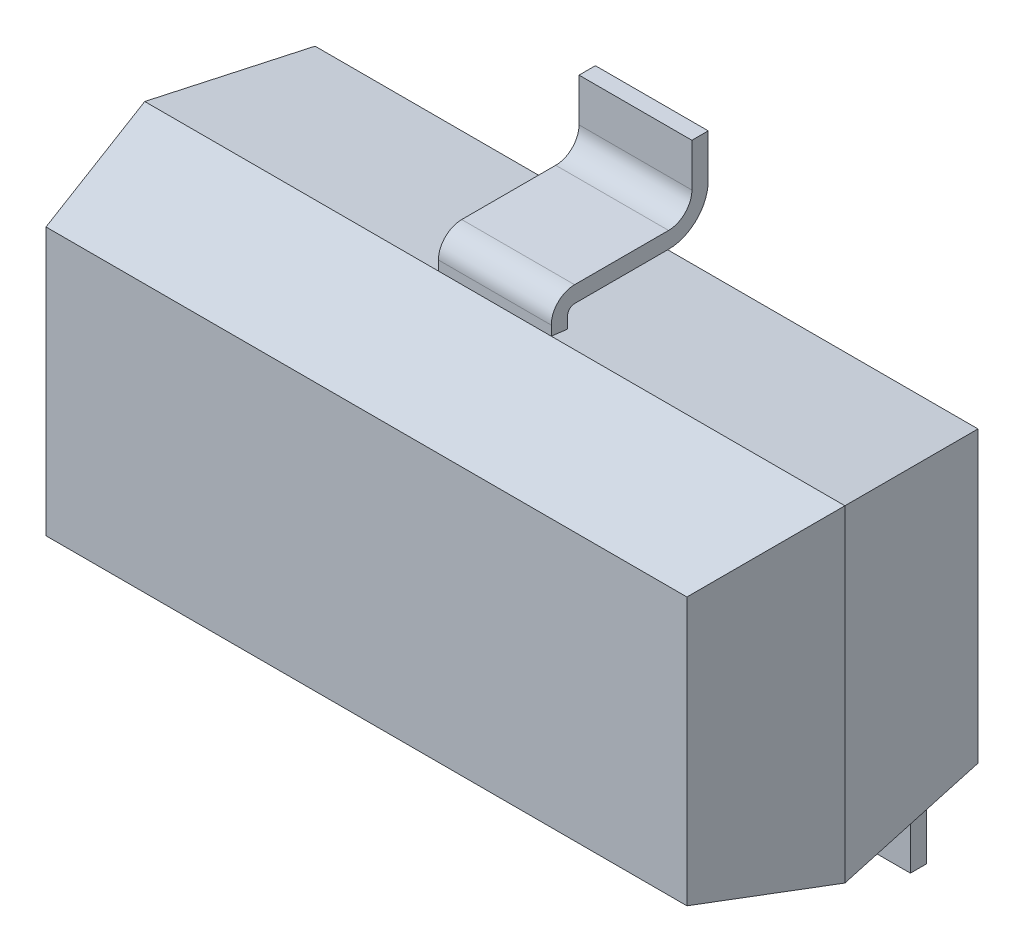
from build123d import *

# Parameters (mm, degrees)
CROQUIS1_W                        = 3
CROQUIS1_H                        = 1.4
SALIENTE_EXTRUIR1_DEPTH           = 0.55
SALIENTE_EXTRUIR1_TAPER           = 13
SALIENTE_EXTRUIR1_OTHER_WAY_DEPTH = 0.65
SALIENTE_EXTRUIR1_OTHER_WAY_TAPER = 7
CROQUIS5_W                        = 0.48350588
CROQUIS5_H                        = 0.55271101
SALIENTE_EXTRUIR5_DEPTH           = 0.69
CORTAR_EXTRUIR2_DEPTH             = 2.69


with BuildPart() as part:
    # Croquis1 → Saliente-Extruir1 (new body)
    with BuildSketch(Plane.XY):
        Rectangle(CROQUIS1_W, CROQUIS1_H)
    extrude(amount=SALIENTE_EXTRUIR1_DEPTH, taper=SALIENTE_EXTRUIR1_TAPER)

    # Croquis1 → Saliente-Extruir1 other way (add)
    with BuildSketch(Plane.XY):
        Rectangle(CROQUIS1_W, CROQUIS1_H)
    extrude(amount=-SALIENTE_EXTRUIR1_OTHER_WAY_DEPTH, taper=SALIENTE_EXTRUIR1_OTHER_WAY_TAPER)

    # Croquis5 → Saliente-Extruir5 (add)
    with BuildSketch(Plane.XY):
        with Locations((-0.936243204, -0.849378)):
            Rectangle(CROQUIS5_W, CROQUIS5_H)
        with Locations((0.936243204, -0.849378)):
            Rectangle(CROQUIS5_W, CROQUIS5_H)
        with Locations((0, 0.849378)):
            Rectangle(CROQUIS5_W, CROQUIS5_H)
    extrude(amount=-SALIENTE_EXTRUIR5_DEPTH)

    # Croquis7 → Cortar-Extruir2 (cut)
    with BuildSketch(Plane.ZY.offset(1.177996144)):
        with BuildLine():
            Line((-0.602582914, -1.125733505), (0, -1.125733505))
            Line((0, -1.125733505), (0, -0.741148346))
            ThreePointArc((0, -0.741148346), (-0.029289322, -0.811859024), (-0.1, -0.841148346))
            Line((-0.1, -0.841148346), (-0.502582914, -0.841148346))
            ThreePointArc((-0.502582914, -0.841148346), (-0.573293592, -0.870437668), (-0.602582914, -0.941148346))
            Line((-0.602582914, -0.941148346), (-0.602582914, -1.125733505))
        make_face()
        with BuildLine():
            Line((-0.07, -0.691405081), (-0.07, -0.741148346))
            ThreePointArc((-0.07, -0.741148346), (-0.078786797, -0.762361549), (-0.1, -0.771148346))
            Line((-0.1, -0.771148346), (-0.502582914, -0.771148346))
            ThreePointArc((-0.502582914, -0.771148346), (-0.622791067, -0.820940193), (-0.672582914, -0.941148346))
            Line((-0.672582914, -0.941148346), (-0.672582914, -1.125733505))
            Line((-0.672582914, -1.125733505), (-0.69, -1.125733505))
            Line((-0.69, -1.125733505), (-0.69, -0.573022495))
            Line((-0.69, -0.573022495), (-0.65, -0.573022495))
            Line((-0.65, -0.573022495), (-0.65, -0.620190035))
            Line((-0.65, -0.620190035), (-0.07, -0.691405081))
        make_face()
        with BuildLine():
            Line((-0.672582914, 0.941148346), (-0.672582914, 1.125733505))
            Line((-0.672582914, 1.125733505), (-0.69, 1.125733505))
            Line((-0.69, 1.125733505), (-0.69, 0.573022495))
            Line((-0.69, 0.573022495), (-0.65, 0.573022495))
            Line((-0.65, 0.573022495), (-0.65, 0.620190035))
            Line((-0.65, 0.620190035), (-0.07, 0.691405081))
            Line((-0.07, 0.691405081), (-0.07, 0.741148346))
            ThreePointArc((-0.07, 0.741148346), (-0.078786797, 0.762361549), (-0.1, 0.771148346))
            Line((-0.1, 0.771148346), (-0.502582914, 0.771148346))
            ThreePointArc((-0.502582914, 0.771148346), (-0.622791067, 0.820940193), (-0.672582914, 0.941148346))
        make_face()
        with BuildLine():
            Line((0, 1.125733505), (0, 0.741148346))
            ThreePointArc((0, 0.741148346), (-0.029289322, 0.811859024), (-0.1, 0.841148346))
            Line((-0.1, 0.841148346), (-0.502582914, 0.841148346))
            ThreePointArc((-0.502582914, 0.841148346), (-0.573293592, 0.870437668), (-0.602582914, 0.941148346))
            Line((-0.602582914, 0.941148346), (-0.602582914, 1.125733505))
            Line((-0.602582914, 1.125733505), (0, 1.125733505))
        make_face()
    extrude(amount=-CORTAR_EXTRUIR2_DEPTH, mode=Mode.SUBTRACT)


solid = part.part
